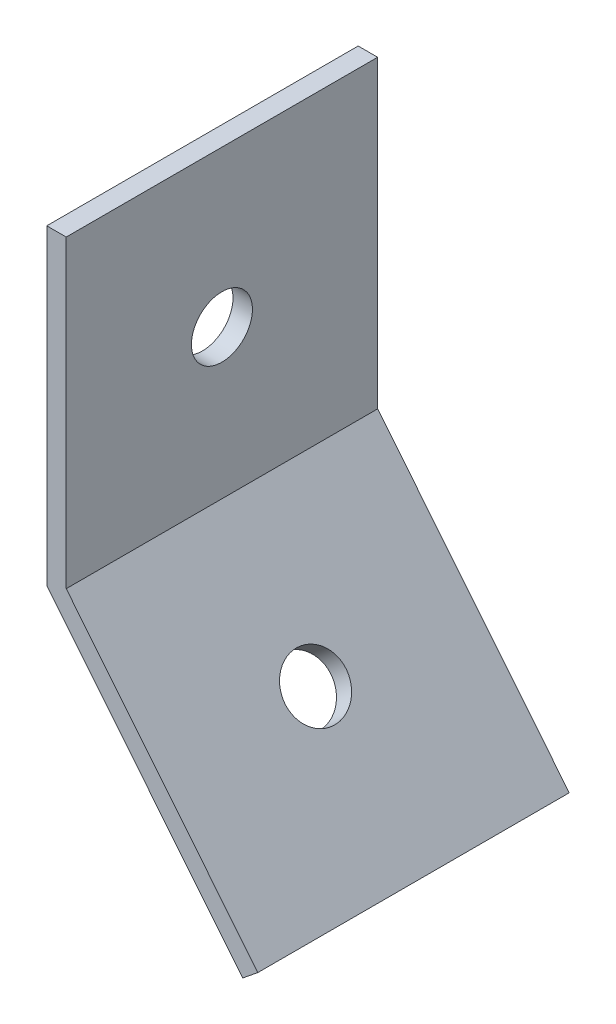
from build123d import *

# Parameters (mm, degrees)
EXTRUDE_THIN1_DEPTH            = 25.4
F_9_0_196_DIAMETER_HOLE1_D     = 4.9784
F_9_0_196_DIAMETER_HOLE1_DEPTH = 1.5885


with BuildPart() as part:
    # Sketch1 → Extrude-Thin1 (new body)
    with BuildSketch(Plane.XY):
        Polygon((50.8, 762), (50.8, 736.6), (66.781992956, 716.858270057), (68.015851078, 717.857144617), (52.3875, 737.162039024), (52.3875, 762), align=None)
    extrude(amount=-EXTRUDE_THIN1_DEPTH)

    # #9 (0.196) Diameter Hole1
    with Locations(Plane(origin=(392.152176242, 317.468293639, 0), x_dir=(0, 0, -1), z_dir=(0.777233462, 0.629212321, 0))):
        with Locations((12.7, 527.846182435)):
            f_9_0_196_diameter_hole1 = Hole(F_9_0_196_DIAMETER_HOLE1_D / 2, depth=F_9_0_196_DIAMETER_HOLE1_DEPTH)

    # Mirror1: #9 (0.196) Diameter Hole1 across plane
    add(f_9_0_196_diameter_hole1.mirror(Plane(origin=(-226.08062781, 638.573091218, 0), x_dir=(0, 0, 1), z_dir=(0.33374132, -0.942664697, 0))), mode=Mode.SUBTRACT)


solid = part.part
